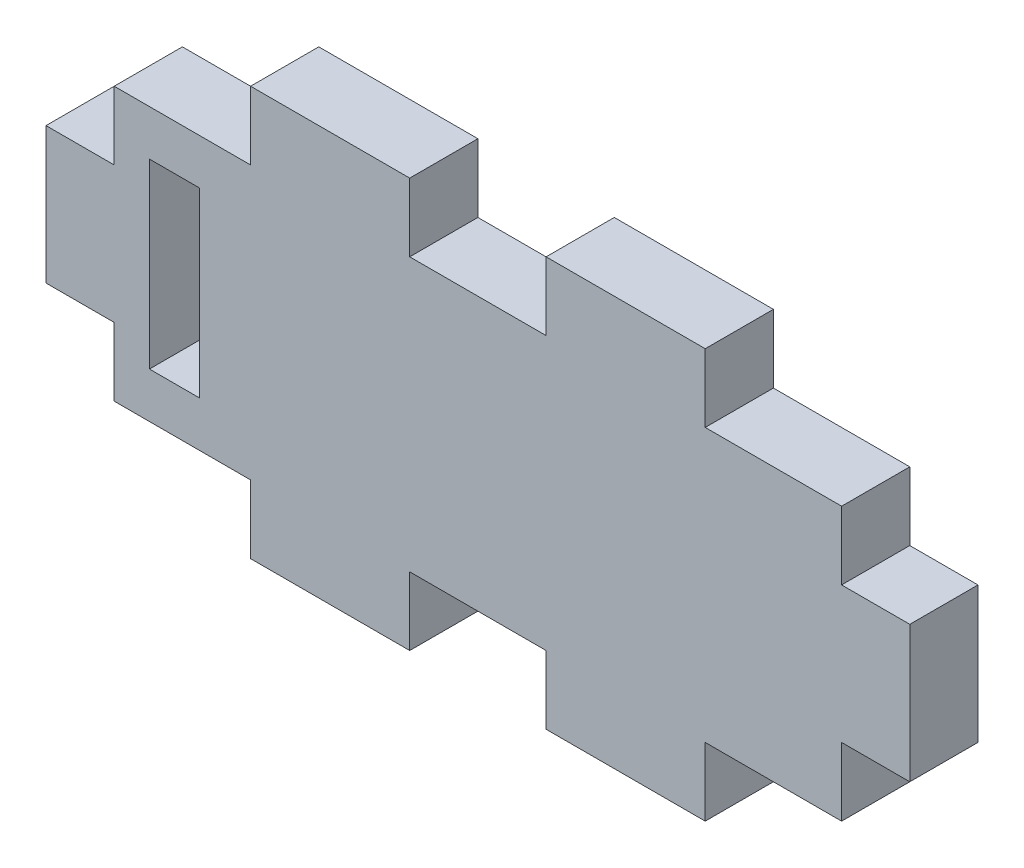
from build123d import *

# Parameters (mm, degrees)
SKETCH2_W           = 32
SKETCH2_H           = 12
BOSS_EXTRUDE1_DEPTH = 3
SKETCH3_W           = 7
SKETCH3_H           = 3
SKETCH3_W_2         = 3
SKETCH3_H_2         = 6
BOSS_EXTRUDE3_DEPTH = 3
SKETCH4_W           = 2.2
SKETCH4_H           = 8
CUT_EXTRUDE1_DEPTH  = 3


with BuildPart() as part:
    # Sketch2 → Boss-Extrude1 (new body)
    with BuildSketch(Plane.XY):
        Rectangle(SKETCH2_W, SKETCH2_H)
    extrude(amount=BOSS_EXTRUDE1_DEPTH)

    # Sketch3 → Boss-Extrude3 (add)
    with BuildSketch(Plane.XY.offset(3)):
        with Locations((-6.5, -7.5)):
            Rectangle(SKETCH3_W, SKETCH3_H)
        with Locations((6.5, -7.5)):
            Rectangle(SKETCH3_W, SKETCH3_H)
        with Locations((6.5, 7.5)):
            Rectangle(SKETCH3_W, SKETCH3_H)
        with Locations((-6.5, 7.5)):
            Rectangle(SKETCH3_W, SKETCH3_H)
        with Locations((-17.5, 0)):
            Rectangle(SKETCH3_W_2, SKETCH3_H_2)
        with Locations((17.5, 0)):
            Rectangle(SKETCH3_W_2, SKETCH3_H_2)
    extrude(amount=-BOSS_EXTRUDE3_DEPTH)

    # Sketch4 → Cut-Extrude1 (cut)
    with BuildSketch(Plane.XY.offset(3)):
        with Locations((-13.35, 0)):
            Rectangle(SKETCH4_W, SKETCH4_H)
    extrude(amount=-CUT_EXTRUDE1_DEPTH, mode=Mode.SUBTRACT)


solid = part.part
